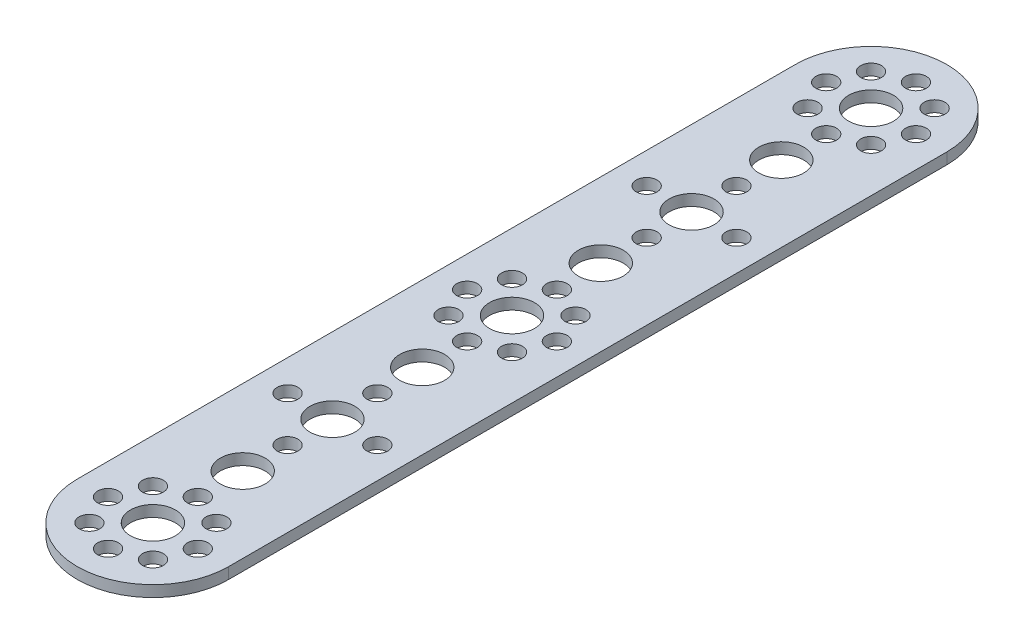
from build123d import *

# Parameters (mm, degrees)
EXTRUDE1_DEPTH = 2
SKETCH2_R      = 4
SKETCH2_R_2    = 1.85
EXTRUDE2_DEPTH = 2


with BuildPart() as part:
    # Sketch1 → Extrude1 (new body)
    with BuildSketch(Plane(origin=(0, 0, 0), x_dir=(1, 0, 0), z_dir=(0, 1, 0))):
        with BuildLine():
            Line((-13.5, 64), (-13.5, -64))
            ThreePointArc((-13.5, -64), (0, -77.5), (13.5, -64))
            Line((13.5, -64), (13.5, 64))
            ThreePointArc((13.5, 64), (0, 77.5), (-13.5, 64))
        make_face()
    extrude(amount=EXTRUDE1_DEPTH)

    # Sketch2 → Extrude2 (cut)
    with BuildSketch(Plane(origin=(0, 2, 0), x_dir=(1, 0, 0), z_dir=(0, 1, 0))):
        with Locations((0, -48)):
            Circle(SKETCH2_R)
        with Locations((0, -16)):
            Circle(SKETCH2_R)
        with Locations((-0.175415159, 16)):
            Circle(SKETCH2_R)
        with Locations((0, 48)):
            Circle(SKETCH2_R)
        with Locations((0, -32)):
            Circle(SKETCH2_R)
        with Locations((0, -24)):
            Circle(SKETCH2_R_2)
        with Locations((0, -40)):
            Circle(SKETCH2_R_2)
        with Locations((8, -32)):
            Circle(SKETCH2_R_2)
        with Locations((-8, -32)):
            Circle(SKETCH2_R_2)
        with Locations((0, -56)):
            Circle(SKETCH2_R_2)
        with Locations((8, -64)):
            Circle(SKETCH2_R_2)
        with Locations((0, -64)):
            Circle(SKETCH2_R)
        with Locations((-8, -64)):
            Circle(SKETCH2_R_2)
        with Locations((-5.66, -69.66)):
            Circle(SKETCH2_R_2)
        with Locations((5.66, -69.66)):
            Circle(SKETCH2_R_2)
        with Locations((0, -72)):
            Circle(SKETCH2_R_2)
        with Locations((-5.66, -58.34)):
            Circle(SKETCH2_R_2)
        with Locations((5.66, -58.34)):
            Circle(SKETCH2_R_2)
        with Locations((0, 32)):
            Circle(SKETCH2_R)
        with Locations((0, 40)):
            Circle(SKETCH2_R_2)
        with Locations((0, 24)):
            Circle(SKETCH2_R_2)
        with Locations((8, 32)):
            Circle(SKETCH2_R_2)
        with Locations((-8, 32)):
            Circle(SKETCH2_R_2)
        with Locations((0, 8)):
            Circle(SKETCH2_R_2)
        with Locations((8, 0)):
            Circle(SKETCH2_R_2)
        Circle(SKETCH2_R)
        with Locations((-8, 0)):
            Circle(SKETCH2_R_2)
        with Locations((-5.66, -5.66)):
            Circle(SKETCH2_R_2)
        with Locations((5.66, -5.66)):
            Circle(SKETCH2_R_2)
        with Locations((0, -8)):
            Circle(SKETCH2_R_2)
        with Locations((-5.66, 5.66)):
            Circle(SKETCH2_R_2)
        with Locations((5.66, 5.66)):
            Circle(SKETCH2_R_2)
        with Locations((0, 56)):
            Circle(SKETCH2_R_2)
        with Locations((-8, 64)):
            Circle(SKETCH2_R_2)
        with Locations((0, 64)):
            Circle(SKETCH2_R)
        with Locations((8, 64)):
            Circle(SKETCH2_R_2)
        with Locations((5.66, 69.66)):
            Circle(SKETCH2_R_2)
        with Locations((-5.66, 69.66)):
            Circle(SKETCH2_R_2)
        with Locations((0, 72)):
            Circle(SKETCH2_R_2)
        with Locations((5.66, 58.34)):
            Circle(SKETCH2_R_2)
        with Locations((-5.66, 58.34)):
            Circle(SKETCH2_R_2)
    extrude(amount=-EXTRUDE2_DEPTH, mode=Mode.SUBTRACT)


solid = part.part
